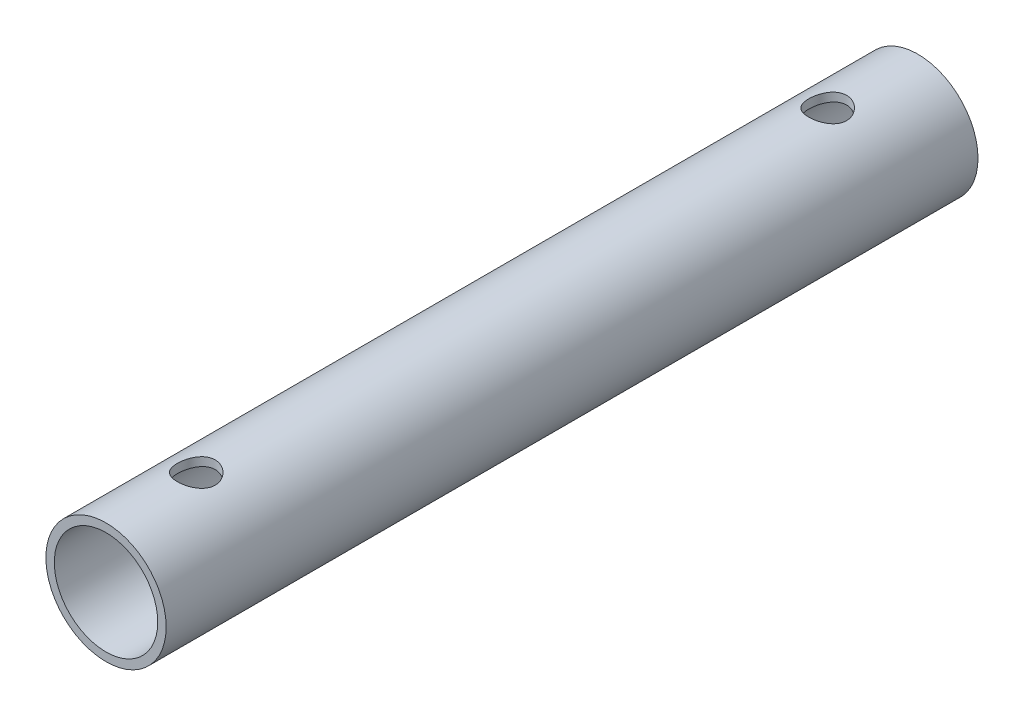
from build123d import *

# Parameters (mm, degrees)
SKETCH1_R               = 6.35
SKETCH1_R_2             = 5.461
EXTRUDE1_DEPTH          = 85.725
SKETCH2_R               = 2
CUT_EXTRUDE1_DEPTH      = 38.1
CUT_EXTRUDE1_DEPTH_BACK = 38.1


with BuildPart() as part:
    # Sketch1 → Extrude1 (new body)
    with BuildSketch(Plane.XY):
        Circle(SKETCH1_R)
        Circle(SKETCH1_R_2, mode=Mode.SUBTRACT)
    extrude(amount=EXTRUDE1_DEPTH)

    # Sketch2 → Cut-Extrude1 (cut, two sides)
    with BuildSketch(Plane(origin=(0, 0, 0), x_dir=(1, 0, 0), z_dir=(0, 1, 0))) as cut_extrude1_sk:
        with Locations(Location((0, -9.525, 0), (0, 0, 270))):  # turned: the seam where the file's is
            Circle(SKETCH2_R)
        with Locations(Location((0, -76.2, 0), (0, 0, 270))):  # turned: the seam where the file's is
            Circle(SKETCH2_R)
    extrude(amount=CUT_EXTRUDE1_DEPTH, mode=Mode.SUBTRACT)
    extrude(cut_extrude1_sk.sketch, amount=-CUT_EXTRUDE1_DEPTH_BACK, mode=Mode.SUBTRACT)


solid = part.part
